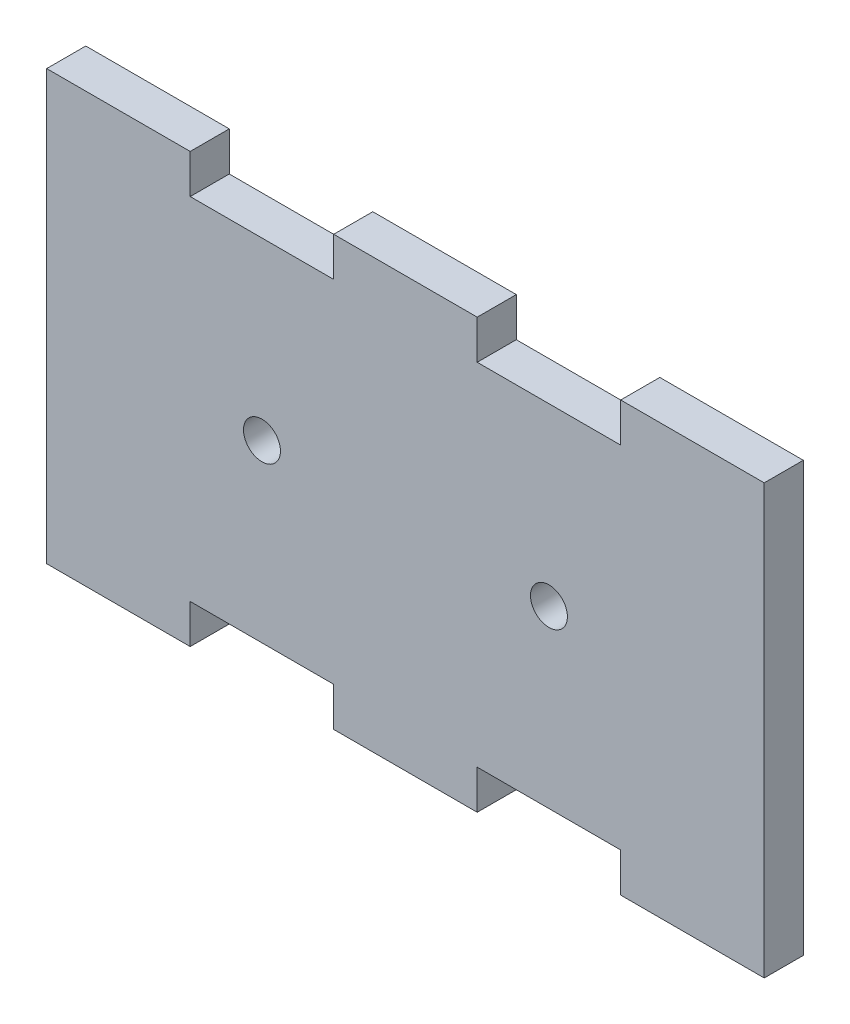
from build123d import *

# Parameters (mm, degrees)
BOSS_EXTRUDE1_DEPTH = 3.175


with BuildPart() as part:
    # Sketch1 → Boss-Extrude1 (new body)
    with BuildSketch(Plane.XY):
        with BuildLine():
            Line((18.985, 0), (29.14, 0))
            Line((29.14, 0), (29.14, 14.24))
            Line((29.14, 14.24), (29.14, 17.415))
            Line((29.14, 17.415), (23.312, 17.415))
            Line((23.312, 17.415), (23.312, 14.24))
            Line((23.312, 14.24), (11.656, 14.24))
            Line((11.656, 14.24), (11.656, 17.415))
            Line((11.656, 17.415), (0, 17.415))
            Line((0, 17.415), (0, 14.24))
            Line((0, 14.24), (0, 0))
            Line((0, 0), (15.985, 0))
            ThreePointArc((15.985, 0), (17.485, 1.5), (18.985, 0))
        make_face()
    extrude(amount=BOSS_EXTRUDE1_DEPTH)

    # Mirror1: part across plane


with BuildPart() as part_1:
    add(part.part)
    add(part.part.mirror(Plane(origin=(0, 0, 3.175), x_dir=(0, 0, 1), z_dir=(0, 1, 0))))

    # Mirror3: part across plane


with BuildPart() as part_2:
    add(part_1.part)
    add(part_1.part.mirror(Plane(origin=(29.14, 14.24, 3.175), x_dir=(0, 0, 1), z_dir=(-1, 0, 0))))


solid = part_2.part
